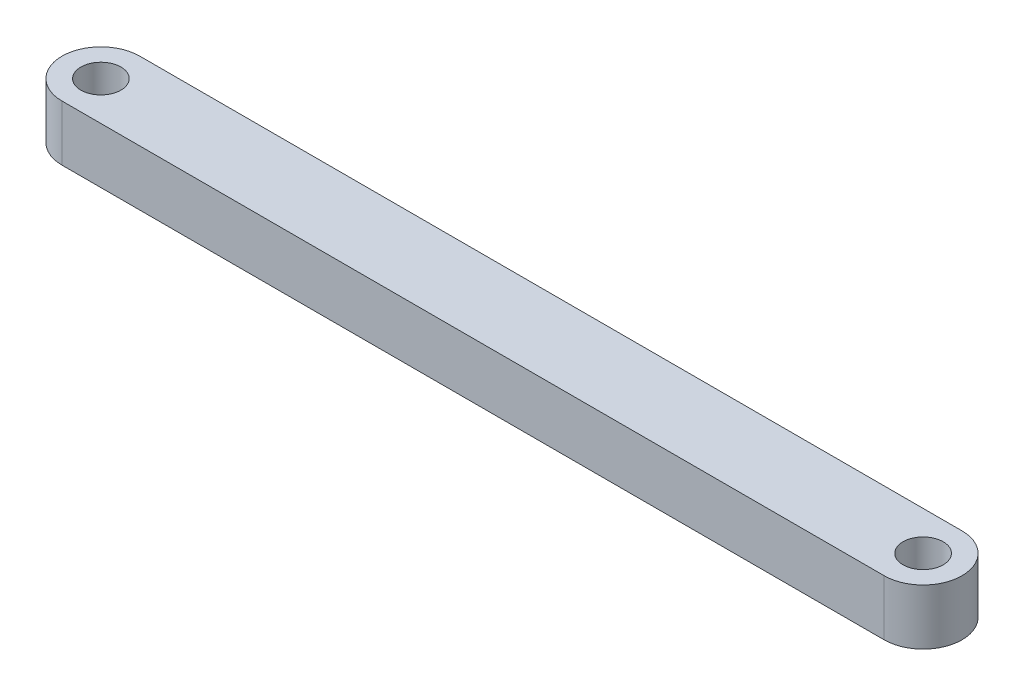
from build123d import *

# Parameters (mm, degrees)
SKETCH1_R           = 2.29235
BOSS_EXTRUDE1_DEPTH = 6.35


with BuildPart() as part:
    # Sketch1 → Boss-Extrude1 (new body)
    with BuildSketch(Plane(origin=(0, 0, 0), x_dir=(1, 0, 0), z_dir=(0, 1, 0))):
        with BuildLine():
            Line((4.445, 8.89), (98.425, 8.89))
            ThreePointArc((98.425, 8.89), (102.87, 4.445), (98.425, 0))
            Line((98.425, 0), (4.445, 0))
            ThreePointArc((4.445, 0), (0, 4.445), (4.445, 8.89))
        make_face()
        with Locations((4.445, 4.445)):
            Circle(SKETCH1_R, mode=Mode.SUBTRACT)
        with Locations((98.425, 4.445)):
            Circle(SKETCH1_R, mode=Mode.SUBTRACT)
    extrude(amount=BOSS_EXTRUDE1_DEPTH)


solid = part.part
